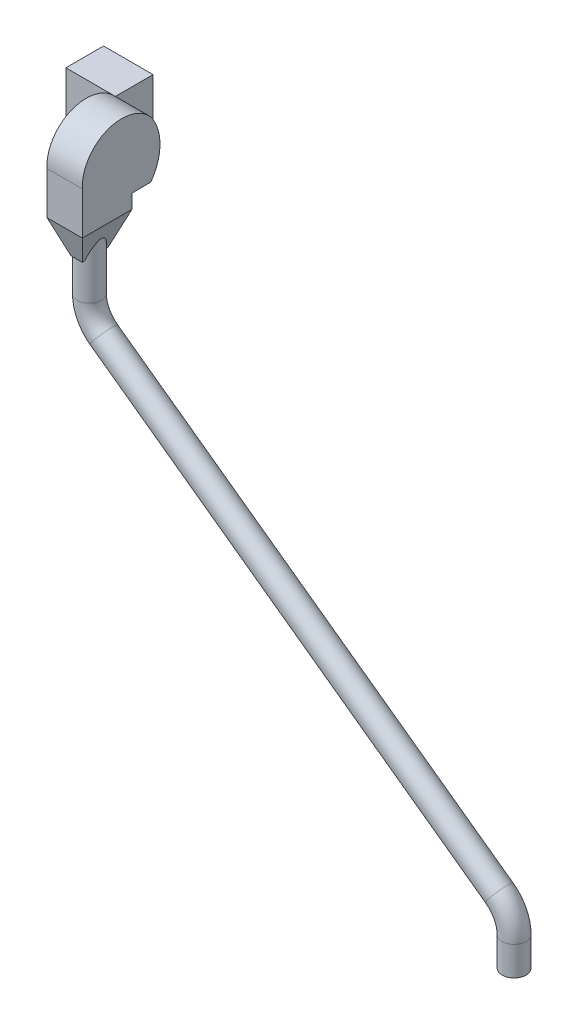
from build123d import *

# Parameters (mm, degrees)
CROQUIS1_W              = 210
CROQUIS1_H              = 240
SALIENTE_EXTRUIR1_DEPTH = 160
SALIENTE_EXTRUIR2_DEPTH = 150
CROQUIS3_W              = 150
CROQUIS3_H              = 210.142141412
SALIENTE_EXTRUIR3_DEPTH = 60
CROQUIS4_R              = 50.8
SALIENTE_EXTRUIR4_DEPTH = 170
CROQUIS5_W              = 150
CROQUIS5_H              = 210.142141412
SALIENTE_EXTRUIR5_DEPTH = 140
SALIENTE_EXTRUIR5_TAPER = 20
CROQUIS7_R              = 50.8


with BuildPart() as part:
    # Croquis1 → Saliente-Extruir1 (new body)
    with BuildSketch(Plane.XY):
        Rectangle(CROQUIS1_W, CROQUIS1_H)
    extrude(amount=SALIENTE_EXTRUIR1_DEPTH)


with BuildPart() as body_2:
    # Croquis2 → Saliente-Extruir2 (new body)
    with BuildSketch(Plane(origin=(105, 0, 0), x_dir=(0, 0, -1), z_dir=(1, 0, 0))):
        with BuildLine():
            Line((-160, -120), (-450, -120))
            Line((-450, -120), (-450, 0))
            ThreePointArc((-450, 0), (-347.372372038, 162.399899092), (-160, 120))
            ThreePointArc((-160, 120), (-120.80959106, 0), (-160, -120))
        make_face()
    extrude(amount=SALIENTE_EXTRUIR2_DEPTH)

    # Croquis3 → Saliente-Extruir3 (add)
    with BuildSketch(Plane.XZ.offset(120)):
        with Locations((180, 344.928929294)):
            Rectangle(CROQUIS3_W, CROQUIS3_H)
    extrude(amount=SALIENTE_EXTRUIR3_DEPTH)

    # Croquis4 → Saliente-Extruir4 (add)
    with BuildSketch(Plane.XZ.offset(180)):
        with Locations((180, 344.928929294)):
            Circle(CROQUIS4_R)
    extrude(amount=SALIENTE_EXTRUIR4_DEPTH)

    # Croquis5 → Saliente-Extruir5 (add)
    with BuildSketch(Plane.XZ.offset(180)):
        with Locations((180, 344.928929294)):
            Rectangle(CROQUIS5_W, CROQUIS5_H)
    extrude(amount=SALIENTE_EXTRUIR5_DEPTH, taper=SALIENTE_EXTRUIR5_TAPER)

    # Barrer1: sweep along a curve in space
    with BuildLine() as barrer1_path:
        Line((1980, -2050, 344.928929294), (1980, -1926.69669426, 344.928929294))
        ThreePointArc((1980, -1926.69669426, 344.928929294), (1963.554366199, -1858.408838317, 344.928929294), (1917.823583077, -1805.09481, 344.928929294))
        Line((1917.823583077, -1805.09481, 344.928929294), (242.176416923, -594.90519, 344.928929294))
        ThreePointArc((242.176416923, -594.90519, 344.928929294), (196.445633801, -541.591161683, 344.928929294), (180, -473.30330574, 344.928929294))
        Line((180, -473.30330574, 344.928929294), (180, -350, 344.928929294))
    # Croquis7 → Barrer1 (sweep)
    with BuildSketch(Plane.XZ.offset(350)):
        with Locations((180, 344.928929294)):
            Circle(CROQUIS7_R)
    sweep(path=barrer1_path.line)


solid = Compound([part.part, body_2.part])
